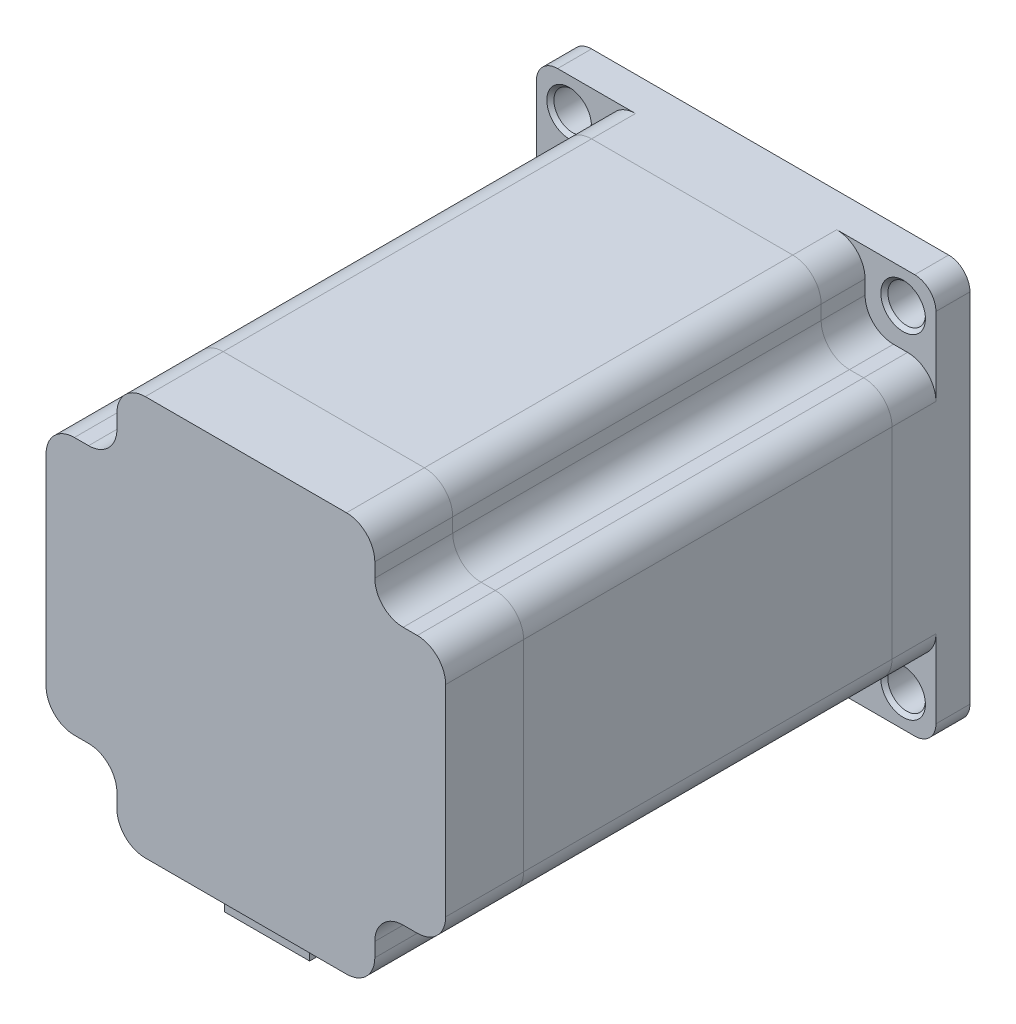
from build123d import *

# Parameters (mm, degrees)
SKETCH_1_W                  = 56.4
SKETCH_1_H                  = 56.4
EXTRUDE_1_DEPTH             = 11
SKETCH_2_W                  = 56.4
SKETCH_2_H                  = 56.4
EXTRUDE_2_DEPTH             = 52
SKETCH_3_W                  = 56.4
SKETCH_3_H                  = 56.4
EXTRUDE_3_DEPTH             = 11
SKETCH_4_R                  = 19.05
EXTRUDE_4_DEPTH             = 1.6
SKETCH_5_R                  = 5
CUT_EXTRUDE_1_DEPTH         = 5
SKETCH_6_R                  = 3.175
EXTRUDE_5_DEPTH             = 25.4
CUT_EXTRUDE_2_DEPTH         = 20
SKETCH_8_W                  = 10
SKETCH_8_H                  = 10
CUT_EXTRUDE_3_DEPTH         = 69.2
PATTERN_CIRCULAR_1_COUNT    = 4
SKETCH_11_W                 = 2.65
SKETCH_11_H                 = 26.8
HOLE_WIZARD_M5_1_AT_2_COUNT = 2
HOLE_WIZARD_M5_1_AT_2_PITCH = 66.66602733
HOLE_WIZARD_M5_1_AT_3_COUNT = 2
HOLE_WIZARD_M5_1_AT_3_PITCH = 47.14
HOLE_WIZARD_M5_1_AT_4_COUNT = 2
HOLE_WIZARD_M5_1_AT_4_PITCH = 47.14
CHAMFER_1_SIZE              = 0.5
FILLET_1_R                  = 3
FILLET_2_R                  = 4
FILLET_3_R                  = 4
FILLET_4_R                  = 4
SKETCH_12_W                 = 12
SKETCH_12_H                 = 5
EXTRUDE_6_DEPTH             = 4
SKETCH_13_R                 = 0.8
EXTRUDE_7_DEPTH             = 10
PATTERN_LINEAR_1_COUNT      = 3
PATTERN_LINEAR_1_PITCH      = 3
PATTERN_LINEAR_1_COL_COUNT  = 2
PATTERN_LINEAR_1_COL_PITCH  = 3


with BuildPart() as part:
    # 草圖1 → 填料-伸長1 (new body)
    with BuildSketch(Plane.XY):
        Rectangle(SKETCH_1_W, SKETCH_1_H)
    extrude(amount=EXTRUDE_1_DEPTH)

    # 草圖4 → 填料-伸長4 (add)
    with BuildSketch(Plane(origin=(0, 0, 0), x_dir=(-1, 0, 0), z_dir=(0, 0, -1))):
        Circle(SKETCH_4_R)
    extrude(amount=EXTRUDE_4_DEPTH)

    # 草圖5 → 除料-伸長1 (cut)
    with BuildSketch(Plane(origin=(0, 0, -1.6), x_dir=(-1, 0, 0), z_dir=(0, 0, -1))):
        Circle(SKETCH_5_R)
    extrude(amount=-CUT_EXTRUDE_1_DEPTH, mode=Mode.SUBTRACT)


with BuildPart() as body_2:
    # 草圖2 → 填料-伸長2 (new body)
    with BuildSketch(Plane.XY.offset(11)):
        Rectangle(SKETCH_2_W, SKETCH_2_H)
    extrude(amount=EXTRUDE_2_DEPTH)


with BuildPart() as body_3:
    # 草圖3 → 填料-伸長3 (new body)
    with BuildSketch(Plane.XY.offset(63)):
        Rectangle(SKETCH_3_W, SKETCH_3_H)
    extrude(amount=EXTRUDE_3_DEPTH)


with BuildPart() as body_4:
    # 草圖6 → 填料-伸長5 (new body)
    with BuildSketch(Plane(origin=(0, 0, 3.4), x_dir=(-1, 0, 0), z_dir=(0, 0, -1))):
        Circle(SKETCH_6_R)
    extrude(amount=EXTRUDE_5_DEPTH)

    # 草圖7 → 除料-伸長2 (cut)
    with BuildSketch(Plane(origin=(0, 0, -22), x_dir=(-1, 0, 0), z_dir=(0, 0, -1))):
        with BuildLine():
            Line((-1.710263138, 2.675), (1.710263138, 2.675))
            ThreePointArc((1.710263138, 2.675), (0, 3.175), (-1.710263138, 2.675))
        make_face()
    extrude(amount=-CUT_EXTRUDE_2_DEPTH, mode=Mode.SUBTRACT)


with BuildPart() as cut_extrude_3_tool:
    # 草圖8 → 除料-伸長3 (new body)
    with BuildSketch(Plane.XY.offset(74)):
        with Locations((23.2, 23.2)):
            Rectangle(SKETCH_8_W, SKETCH_8_H)
    cut_extrude_3 = extrude(amount=-CUT_EXTRUDE_3_DEPTH)


with BuildPart() as part_1:
    add(part.part)

    # 除料-伸長3: cut by cut_extrude_3_tool
    add(cut_extrude_3_tool.part, mode=Mode.SUBTRACT)


with BuildPart() as body_2_1:
    add(body_2.part)

    # 除料-伸長3: cut by cut_extrude_3_tool
    add(cut_extrude_3_tool.part, mode=Mode.SUBTRACT)


with BuildPart() as body_3_1:
    add(body_3.part)

    # 除料-伸長3: cut by cut_extrude_3_tool
    add(cut_extrude_3_tool.part, mode=Mode.SUBTRACT)


with BuildPart() as pattern_circular_1_tool:
    # 環狀複製排列1: 除料-伸長3 ×4 about axis
    pattern_circular_1_axis = Axis((0, 0, 0), (0, 0, 1))
    for i in range(1, PATTERN_CIRCULAR_1_COUNT):
        add(cut_extrude_3.rotate(pattern_circular_1_axis, i * 360 / PATTERN_CIRCULAR_1_COUNT))


with BuildPart() as part_2:
    add(part_1.part)

    # 環狀複製排列1: cut by pattern_circular_1_tool
    add(pattern_circular_1_tool.part, mode=Mode.SUBTRACT)

    # 草圖11 → M5 餘隙孔1 (revolve, cut)
    with BuildSketch(Plane(origin=(23.57, 23.57, 4.8), x_dir=(0, -1, 0), z_dir=(1, 0, 0))):
        with Locations((1.325, 13.4)):
            Rectangle(SKETCH_11_W, SKETCH_11_H)
    hole_wizard_m5_1 = revolve(axis=Axis((23.57, 23.57, 11.15), (0, 0, -1)), mode=Mode.SUBTRACT)

    # M5 餘隙孔1 at 2: M5 餘隙孔1 ×2
    with Locations(*[Vector(-0.707106781, -0.707106781, 0) * (i * HOLE_WIZARD_M5_1_AT_2_PITCH) for i in range(1, HOLE_WIZARD_M5_1_AT_2_COUNT)]):
        add(hole_wizard_m5_1, mode=Mode.SUBTRACT)

    # M5 餘隙孔1 at 3: M5 餘隙孔1 ×2
    with Locations(*[(-i * HOLE_WIZARD_M5_1_AT_3_PITCH, 0, 0) for i in range(1, HOLE_WIZARD_M5_1_AT_3_COUNT)]):
        add(hole_wizard_m5_1, mode=Mode.SUBTRACT)

    # M5 餘隙孔1 at 4: M5 餘隙孔1 ×2
    with Locations(*[(0, -i * HOLE_WIZARD_M5_1_AT_4_PITCH, 0) for i in range(1, HOLE_WIZARD_M5_1_AT_4_COUNT)]):
        add(hole_wizard_m5_1, mode=Mode.SUBTRACT)

    # 導角1
    chamfer_1_edges = [part_2.edges().sort_by_distance(p)[0] for p in [
        (23.57, -20.92, 0),
        (23.57, -20.92, 4.8),
        (-23.57, 26.22, 0),
        (-23.57, 26.22, 4.8),
        (-23.57, -20.92, 0),
        (-23.57, -20.92, 4.8),
        (23.57, 26.22, 0),
        (23.57, 26.22, 4.8),
    ]]
    chamfer(chamfer_1_edges, length=CHAMFER_1_SIZE)

    # 圓角1
    fillet_1_edges = [part_2.edges().sort_by_distance(p)[0] for p in [
        (28.2, 28.2, 2.4),
        (28.2, -28.2, 2.4),
        (-28.2, -28.2, 2.4),
        (-28.2, 28.2, 2.4),
    ]]
    fillet(fillet_1_edges, radius=FILLET_1_R)

    # 圓角2
    fillet_2_edges = [part_2.edges().sort_by_distance(p)[0] for p in [
        (18.2, 28.2, 7.9),
        (18.2, 18.2, 7.9),
        (28.2, 18.2, 7.9),
        (28.2, -18.2, 7.9),
        (18.2, -18.2, 7.9),
        (18.2, -28.2, 7.9),
        (-18.2, -28.2, 7.9),
        (-18.2, -18.2, 7.9),
        (-28.2, -18.2, 7.9),
        (-28.2, 18.2, 7.9),
        (-18.2, 18.2, 7.9),
        (-18.2, 28.2, 7.9),
    ]]
    fillet(fillet_2_edges, radius=FILLET_2_R)


with BuildPart() as body_2_2:
    add(body_2_1.part)

    # 環狀複製排列1: cut by pattern_circular_1_tool
    add(pattern_circular_1_tool.part, mode=Mode.SUBTRACT)

    # 圓角3
    fillet_3_edges = [body_2_2.edges().sort_by_distance(p)[0] for p in [
        (18.2, 28.2, 37),
        (18.2, 18.2, 37),
        (28.2, 18.2, 37),
        (28.2, -18.2, 37),
        (18.2, -18.2, 37),
        (18.2, -28.2, 37),
        (-18.2, -28.2, 37),
        (-18.2, -18.2, 37),
        (-28.2, -18.2, 37),
        (-28.2, 18.2, 37),
        (-18.2, 18.2, 37),
        (-18.2, 28.2, 37),
    ]]
    fillet(fillet_3_edges, radius=FILLET_3_R)


with BuildPart() as body_3_2:
    add(body_3_1.part)

    # 環狀複製排列1: cut by pattern_circular_1_tool
    add(pattern_circular_1_tool.part, mode=Mode.SUBTRACT)

    # 圓角4
    fillet_4_edges = [body_3_2.edges().sort_by_distance(p)[0] for p in [
        (18.2, 28.2, 68.5),
        (18.2, 18.2, 68.5),
        (28.2, 18.2, 68.5),
        (28.2, -18.2, 68.5),
        (18.2, -18.2, 68.5),
        (18.2, -28.2, 68.5),
        (-18.2, -28.2, 68.5),
        (-18.2, -18.2, 68.5),
        (-28.2, -18.2, 68.5),
        (-28.2, 18.2, 68.5),
        (-18.2, 18.2, 68.5),
        (-18.2, 28.2, 68.5),
    ]]
    fillet(fillet_4_edges, radius=FILLET_4_R)


with BuildPart() as body_5:
    # 草圖12 → 填料-伸長6 (new body)
    with BuildSketch(Plane.XZ.offset(28.2)):
        with Locations((0, 68.5)):
            Rectangle(SKETCH_12_W, SKETCH_12_H)
    extrude(amount=EXTRUDE_6_DEPTH)


with BuildPart() as body_6:
    # 草圖13 → 填料-伸長7 (new body)
    with BuildSketch(Plane(origin=(0, 0, 66), x_dir=(-1, 0, 0), z_dir=(0, 0, -1))):
        with Locations((1.5, -30.2)):
            Circle(SKETCH_13_R)
    extrude_7 = extrude(amount=EXTRUDE_7_DEPTH)


with BuildPart() as pattern_linear_1_1:
    # 直線複製排列1: 填料-伸長7 ×3
    with Locations(*[(i * PATTERN_LINEAR_1_PITCH, 0, 0) for i in range(1, PATTERN_LINEAR_1_COUNT)]):
        add(extrude_7)


with BuildPart() as pattern_linear_1_col_1:
    # 直線複製排列1 col: 填料-伸長7 ×2
    with Locations(*[(-i * PATTERN_LINEAR_1_COL_PITCH, 0, 0) for i in range(1, PATTERN_LINEAR_1_COL_COUNT)]):
        add(extrude_7)


solid = Compound([body_4.part, part_2.part, body_2_2.part, body_3_2.part, body_5.part, body_6.part, pattern_linear_1_1.part, pattern_linear_1_col_1.part])
